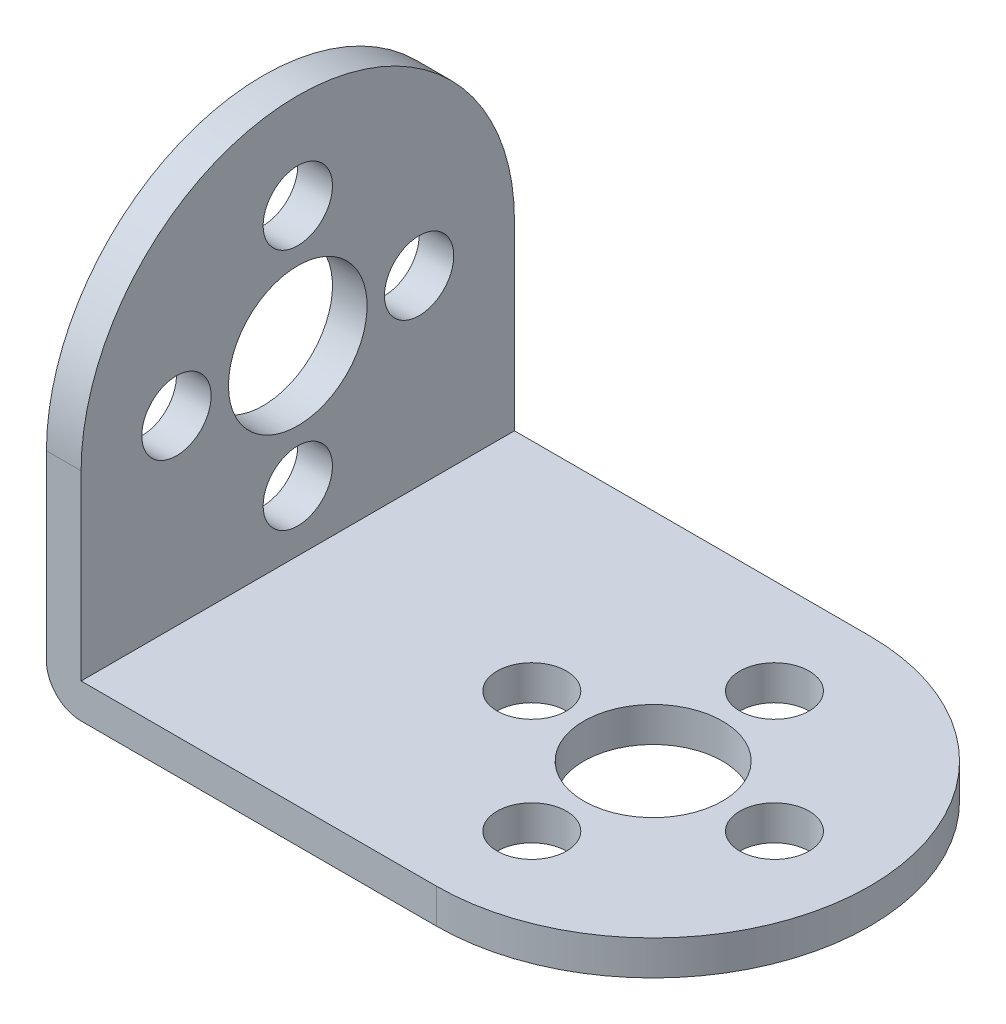
from build123d import *

# Parameters (mm, degrees)
SKETCH_1_R      = 4
SKETCH_1_R_2    = 2
EXTRUDE_1_DEPTH = 2
SKETCH_2_R      = 4
SKETCH_2_R_2    = 2
EXTRUDE_2_DEPTH = 2
FILLET_1_R      = 2


with BuildPart() as part:
    # 草图1 → 凸台-拉伸1 (new body)
    with BuildSketch(Plane(origin=(0, 0, 0), x_dir=(1, 0, 0), z_dir=(0, 1, 0))):
        with BuildLine():
            Line((-11.25, 12.5), (11.25, 12.5))
            ThreePointArc((11.25, 12.5), (23.75, 0), (11.25, -12.5))
            Line((11.25, -12.5), (-11.25, -12.5))
            Line((-11.25, -12.5), (-11.25, 12.5))
        make_face()
        with Locations((11.25, 0)):
            Circle(SKETCH_1_R, mode=Mode.SUBTRACT)
        with Locations((18.25, 0)):
            Circle(SKETCH_1_R_2, mode=Mode.SUBTRACT)
        with Locations((11.25, -7)):
            Circle(SKETCH_1_R_2, mode=Mode.SUBTRACT)
        with Locations((4.25, 0)):
            Circle(SKETCH_1_R_2, mode=Mode.SUBTRACT)
        with Locations((11.25, 7)):
            Circle(SKETCH_1_R_2, mode=Mode.SUBTRACT)
    extrude(amount=EXTRUDE_1_DEPTH)

    # 草图2 → 凸台-拉伸2 (add)
    with BuildSketch(Plane.ZY.offset(11.25)):
        with BuildLine():
            Line((-12.5, 0), (12.5, 0))
            Line((12.5, 0), (12.5, 12.5))
            ThreePointArc((12.5, 12.5), (0, 25), (-12.5, 12.5))
            Line((-12.5, 12.5), (-12.5, 0))
        make_face()
        with Locations((0, 12.5)):
            Circle(SKETCH_2_R, mode=Mode.SUBTRACT)
        with Locations((0, 19.5)):
            Circle(SKETCH_2_R_2, mode=Mode.SUBTRACT)
        with Locations((7, 12.5)):
            Circle(SKETCH_2_R_2, mode=Mode.SUBTRACT)
        with Locations((0, 5.5)):
            Circle(SKETCH_2_R_2, mode=Mode.SUBTRACT)
        with Locations((-7, 12.5)):
            Circle(SKETCH_2_R_2, mode=Mode.SUBTRACT)
    extrude(amount=-EXTRUDE_2_DEPTH)

    # 圆角1
    fillet_1_edges = [part.edges().sort_by_distance(p)[0] for p in [
        (-11.25, 0, 0),
    ]]
    fillet(fillet_1_edges, radius=FILLET_1_R)


solid = part.part
